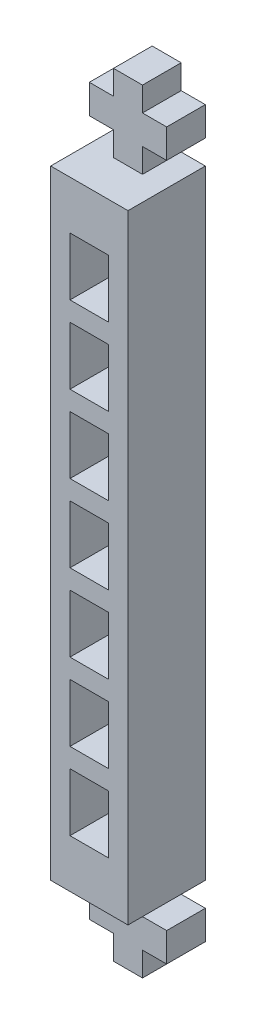
from build123d import *

# Parameters (mm, degrees)
SKETCH1_W           = 20
SKETCH1_H           = 20
BOSS_EXTRUDE1_DEPTH = 200
SKETCH2_W           = 10
SKETCH2_H           = 20
CUT_EXTRUDE1_DEPTH  = 21
SKETCH3_W           = 6.25
SKETCH3_H           = 6.25
CUT_EXTRUDE2_DEPTH  = 21
SKETCH4_W           = 6.25
SKETCH4_H           = 6.25
CUT_EXTRUDE3_DEPTH  = 21
SKETCH5_W           = 10
SKETCH5_H           = 15
CUT_EXTRUDE4_DEPTH  = 21


with BuildPart() as part:
    # Sketch1 → Boss-Extrude1 (new body)
    with BuildSketch(Plane(origin=(0, 0, 0), x_dir=(1, 0, 0), z_dir=(0, 1, 0))):
        with Locations((10, 10)):
            Rectangle(SKETCH1_W, SKETCH1_H)
    extrude(amount=BOSS_EXTRUDE1_DEPTH)

    # Sketch2 → Cut-Extrude1 (cut, through all)
    with BuildSketch(Plane(origin=(20, 0, 0), x_dir=(0, 0, -1), z_dir=(1, 0, 0))):
        with Locations((5, 190)):
            Rectangle(SKETCH2_W, SKETCH2_H)
        with Locations((5, 10)):
            Rectangle(SKETCH2_W, SKETCH2_H)
    extrude(amount=-CUT_EXTRUDE1_DEPTH, mode=Mode.SUBTRACT)

    # Sketch3 → Cut-Extrude2 (cut, through all)
    with BuildSketch(Plane(origin=(0, 0, -20), x_dir=(-1, 0, 0), z_dir=(0, 0, -1))):
        with Locations((-3.125, 196.875)):
            Rectangle(SKETCH3_W, SKETCH3_H)
        with Locations((-16.875, 196.875)):
            Rectangle(SKETCH3_W, SKETCH3_H)
        with Locations((-16.875, 183.125)):
            Rectangle(SKETCH3_W, SKETCH3_H)
        with Locations((-3.125, 183.125)):
            Rectangle(SKETCH3_W, SKETCH3_H)
    extrude(amount=-CUT_EXTRUDE2_DEPTH, mode=Mode.SUBTRACT)

    # Sketch4 → Cut-Extrude3 (cut, through all)
    with BuildSketch(Plane(origin=(0, 0, -20), x_dir=(-1, 0, 0), z_dir=(0, 0, -1))):
        with Locations((-16.875, 16.875)):
            Rectangle(SKETCH4_W, SKETCH4_H)
        with Locations((-16.875, 3.125)):
            Rectangle(SKETCH4_W, SKETCH4_H)
        with Locations((-3.125, 16.875)):
            Rectangle(SKETCH4_W, SKETCH4_H)
        with Locations((-3.125, 3.125)):
            Rectangle(SKETCH4_W, SKETCH4_H)
    extrude(amount=-CUT_EXTRUDE3_DEPTH, mode=Mode.SUBTRACT)

    # Sketch5 → Cut-Extrude4 (cut, through all)
    with BuildSketch(Plane.XY):
        with Locations((10, 40)):
            Rectangle(SKETCH5_W, SKETCH5_H)
        with Locations((10, 60)):
            Rectangle(SKETCH5_W, SKETCH5_H)
        with Locations((10, 80)):
            Rectangle(SKETCH5_W, SKETCH5_H)
        with Locations((10, 100)):
            Rectangle(SKETCH5_W, SKETCH5_H)
        with Locations((10, 120)):
            Rectangle(SKETCH5_W, SKETCH5_H)
        with Locations((10, 140)):
            Rectangle(SKETCH5_W, SKETCH5_H)
        with Locations((10, 160)):
            Rectangle(SKETCH5_W, SKETCH5_H)
    extrude(amount=-CUT_EXTRUDE4_DEPTH, mode=Mode.SUBTRACT)


solid = part.part
